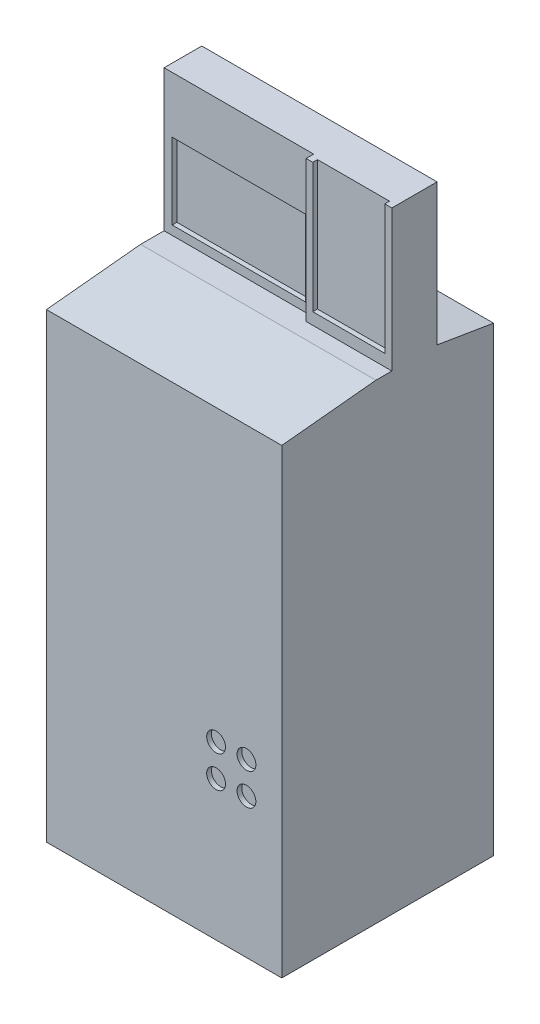
from build123d import *

# Parameters (mm, degrees)
SKETCH2_W                = 500
SKETCH2_H                = 450
BOSS_EXTRUDE1_DEPTH      = 800
BOSS_EXTRUDE1_DEPTH_BACK = 200
CHAMFER1_SIZE            = 20
CHAMFER1_SIZE2           = 200
CHAMFER2_SIZE            = 20
CHAMFER2_SIZE2           = 120
SKETCH9_W                = 317.816050667
SKETCH9_H                = 80.00001522
BOSS_EXTRUDE2_DEPTH      = 300
SKETCH10_W               = 283.451852853
SKETCH10_H               = 161.628693338
CUT_EXTRUDE1_DEPTH       = 10
SKETCH11_R               = 20
CUT_EXTRUDE2_DEPTH       = 10
SKETCH12_W               = 152.997678588
SKETCH12_H               = 274.954886326
CUT_EXTRUDE3_DEPTH       = 10
SKETCH13_W               = 152.997678588
SKETCH13_H               = 17.889097052
BOSS_EXTRUDE3_DEPTH      = 175
SKETCH15_W               = 402.299842062
SKETCH15_H               = 272.648708127
CUT_EXTRUDE4_DEPTH       = 70


with BuildPart() as part:
    # Sketch2 → Boss-Extrude1 (new body, two sides)
    with BuildSketch(Plane(origin=(0, 0, 0), x_dir=(1, 0, 0), z_dir=(0, 1, 0))) as boss_extrude1_sk:
        Rectangle(SKETCH2_W, SKETCH2_H)
    extrude(amount=BOSS_EXTRUDE1_DEPTH)
    extrude(boss_extrude1_sk.sketch, amount=-BOSS_EXTRUDE1_DEPTH_BACK)

    # Chamfer1
    chamfer1_edges = [part.edges().sort_by_distance(p)[0] for p in [
        (0, 800, 225),
    ]]
    chamfer1_side = [part.faces().sort_by_distance(p)[0] for p in [
        (0, 300, 225),
    ]]
    chamfer(chamfer1_edges, length=CHAMFER1_SIZE, length2=CHAMFER1_SIZE2, reference=chamfer1_side[0])

    # Chamfer2
    chamfer2_edges = [part.edges().sort_by_distance(p)[0] for p in [
        (0, 800, -225),
    ]]
    chamfer2_side = [part.faces().sort_by_distance(p)[0] for p in [
        (0, 300, -225),
    ]]
    chamfer(chamfer2_edges, length=CHAMFER2_SIZE, length2=CHAMFER2_SIZE2, reference=chamfer2_side[0])

    # Sketch9 → Boss-Extrude2 (add)
    with BuildSketch(Plane(origin=(0, 800, 0), x_dir=(1, 0, 0), z_dir=(0, 1, 0))):
        with Locations((-91.091974667, 64.99999239)):
            Rectangle(SKETCH9_W, SKETCH9_H)
        Polygon((250, 105), (67.816050667, 105), (67.816050667, 24.99998478), (67.816050667, 8.908040554), (250, 8.908040554), align=None)
    extrude(amount=BOSS_EXTRUDE2_DEPTH)

    # Sketch10 → Cut-Extrude1 (cut)
    with BuildSketch(Plane.XY.offset(-24.99998478)):
        with Locations((-91.091974667, 900)):
            Rectangle(SKETCH10_W, SKETCH10_H)
    extrude(amount=-CUT_EXTRUDE1_DEPTH, mode=Mode.SUBTRACT)

    # Sketch11 → Cut-Extrude2 (cut)
    with BuildSketch(Plane.XY.offset(225)):
        with Locations((110.472474251, 164.751161956)):
            Circle(SKETCH11_R)
        with Locations((174.967964998, 164.751161956)):
            Circle(SKETCH11_R)
        with Locations((110.472474251, 97.062825132)):
            Circle(SKETCH11_R)
        with Locations((174.967964998, 97.062825132)):
            Circle(SKETCH11_R)
    extrude(amount=-CUT_EXTRUDE2_DEPTH, mode=Mode.SUBTRACT)

    # Sketch12 → Cut-Extrude3 (cut)
    with BuildSketch(Plane.XY.offset(-8.908040554)):
        with Locations((158.466067066, 962.522556837)):
            Rectangle(SKETCH12_W, SKETCH12_H)
    extrude(amount=-CUT_EXTRUDE3_DEPTH, mode=Mode.SUBTRACT)

    # Sketch13 → Boss-Extrude3 (add)
    with BuildSketch(Plane(origin=(0, 825.045113674, 0), x_dir=(1, 0, 0), z_dir=(0, 1, 0))):
        with Locations((158.466067066, 96.055451474)):
            Rectangle(SKETCH13_W, SKETCH13_H)
    extrude(amount=BOSS_EXTRUDE3_DEPTH)

    # Sketch15 → Cut-Extrude4 (cut)
    with BuildSketch(Plane(origin=(0, 0, -225), x_dir=(-1, 0, 0), z_dir=(0, 0, -1))):
        with Locations((0.051547356, -27.71868848)):
            Rectangle(SKETCH15_W, SKETCH15_H)
    extrude(amount=-CUT_EXTRUDE4_DEPTH, mode=Mode.SUBTRACT)


solid = part.part
